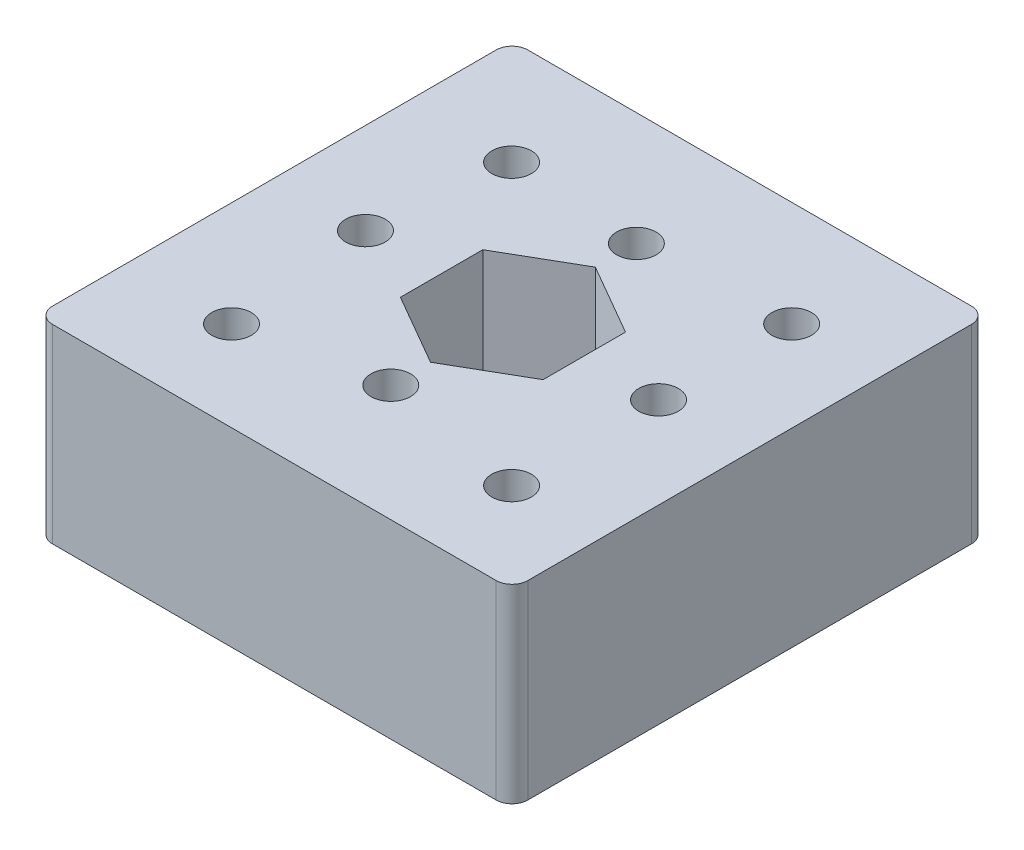
from build123d import *

# Parameters (mm, degrees)
SKETCH1_W           = 30
SKETCH1_H           = 30
SKETCH1_R           = 1.25
BOSS_EXTRUDE2_DEPTH = 12
FILLET1_R           = 1


with BuildPart() as part:
    # Sketch1 → Boss-Extrude2 (new body)
    with BuildSketch(Plane(origin=(0, 0, 0), x_dir=(1, 0, 0), z_dir=(0, 1, 0))):
        Rectangle(SKETCH1_W, SKETCH1_H)
        with Locations((-9.25, 0)):
            Circle(SKETCH1_R, mode=Mode.SUBTRACT)
        with Locations((9.25, 0)):
            Circle(SKETCH1_R, mode=Mode.SUBTRACT)
        with Locations((0, 7.848591319)):
            Circle(SKETCH1_R, mode=Mode.SUBTRACT)
        with Locations((0, -7.651408681)):
            Circle(SKETCH1_R, mode=Mode.SUBTRACT)
        with Locations((9.300881955, 8.35126307)):
            Circle(SKETCH1_R, mode=Mode.SUBTRACT)
        with Locations((9.300881955, -9.32640646)):
            Circle(SKETCH1_R, mode=Mode.SUBTRACT)
        with Locations((-8.376787575, -9.32640646)):
            Circle(SKETCH1_R, mode=Mode.SUBTRACT)
        with Locations((-8.376787575, 8.35126307)):
            Circle(SKETCH1_R, mode=Mode.SUBTRACT)
        Polygon((4.5033321, -2.54076447), (4.5033321, 2.65923553), (0, 5.25923553), (-4.5033321, 2.65923553), (-4.5033321, -2.54076447), (0, -5.14076447), align=None, mode=Mode.SUBTRACT)
    extrude(amount=BOSS_EXTRUDE2_DEPTH)

    # Fillet1
    fillet1_edges = [part.edges().sort_by_distance(p)[0] for p in [
        (15, 6, 15),
        (-15, 6, 15),
        (-15, 6, -15),
        (15, 6, -15),
    ]]
    fillet(fillet1_edges, radius=FILLET1_R)


solid = part.part
